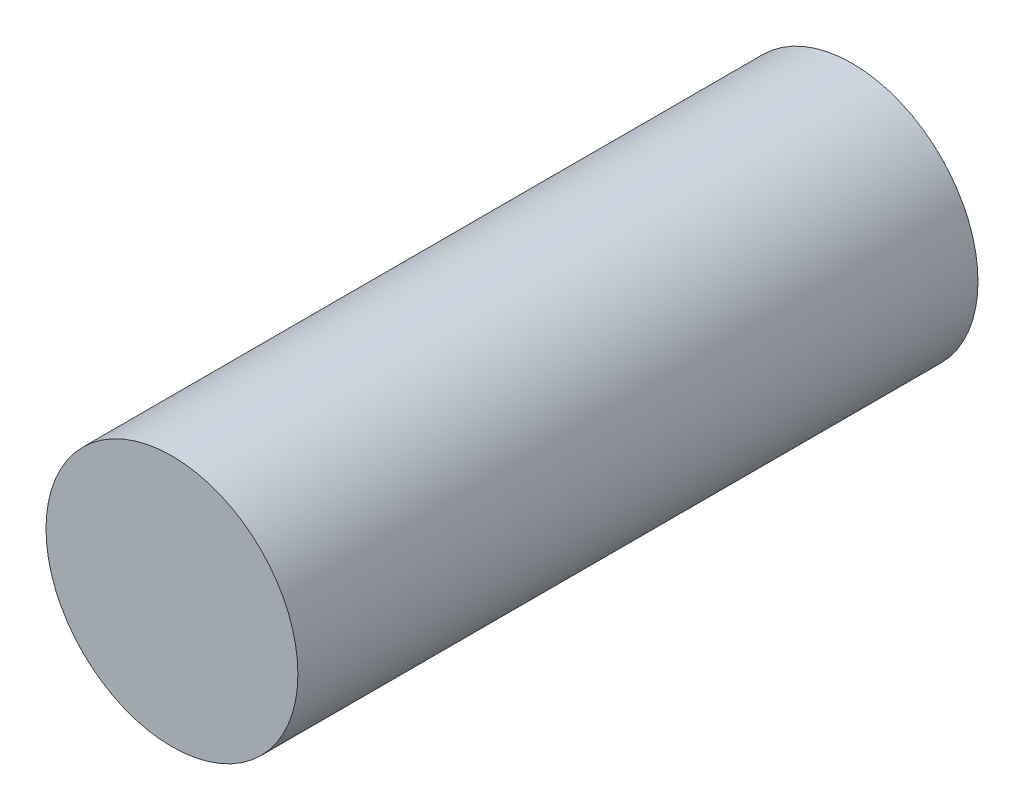
from build123d import *

# Parameters (mm, degrees)
SKETCH1_R           = 6.35
BOSS_EXTRUDE1_DEPTH = 34.29


with BuildPart() as part:
    # Sketch1 → Boss-Extrude1 (new body)
    with BuildSketch(Plane.XY):
        Circle(SKETCH1_R)
    extrude(amount=BOSS_EXTRUDE1_DEPTH)


solid = part.part
